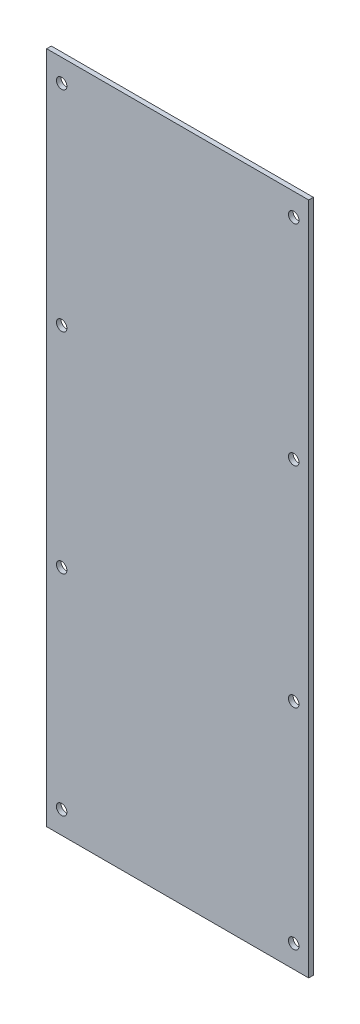
from build123d import *

# Parameters (mm, degrees)
SKETCH1_W            = 88.9
SKETCH1_H            = 228.6
EXTRUDE1_DEPTH       = 1.5748
SKETCH2_R            = 1.778
CUT_EXTRUDE1_DEPTH   = 2.54
LPATTERN1_COUNT      = 2
LPATTERN1_PITCH      = 78.74
LPATTERN1_COUNT_DIR2 = 4
LPATTERN1_PITCH_DIR2 = 71.12


with BuildPart() as part:
    # Sketch1 → Extrude1 (new body)
    with BuildSketch(Plane.XY):
        with Locations((44.45, -114.3)):
            Rectangle(SKETCH1_W, SKETCH1_H)
    extrude(amount=EXTRUDE1_DEPTH)

    # Sketch2 → Cut-Extrude1 (cut)
    with BuildSketch(Plane.XY.offset(1.5748)):
        with Locations((5.08, -7.62)):
            Circle(SKETCH2_R)
    cut_extrude1 = extrude(amount=-CUT_EXTRUDE1_DEPTH, mode=Mode.SUBTRACT)

    # LPattern1: Cut-Extrude1 2 × 4
    with Locations(*[(i * LPATTERN1_PITCH, -j * LPATTERN1_PITCH_DIR2, 0) for i in range(LPATTERN1_COUNT) for j in range(LPATTERN1_COUNT_DIR2) if (i, j) != (0, 0)]):
        add(cut_extrude1, mode=Mode.SUBTRACT)


solid = part.part
